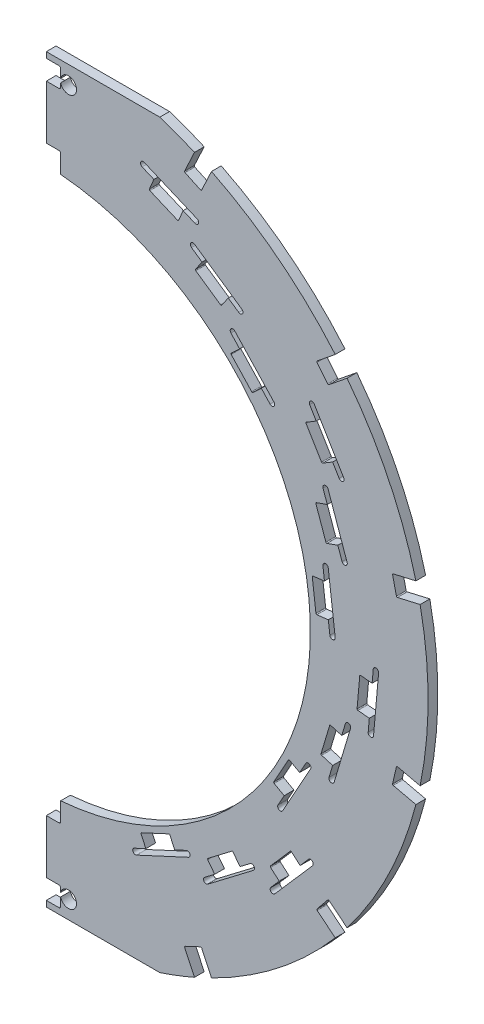
from build123d import *

# Parameters (mm, degrees)
EXTRUDE1_DEPTH                     = 2.715
EXTRUDE3_DEPTH                     = 6.43
CUT_EXTRUDE2_DEPTH                 = 6.43
CIRPATTERN2_COUNT                  = 6
CIRPATTERN2_ANGLE                  = 130
SKETCH9_W                          = 8
SKETCH9_H                          = 11
SKETCH9_H_2                        = 11.120780421
CUT_EXTRUDE3_DEPTH                 = 6.43
FILLET1_R                          = 1
STAVE_MOUNT_HOLE_EXTRUDE4_DEPTH    = 3.715
STAVE_MOUNT_HOLE_CIRPATTERN3_COUNT = 4
STAVE_MOUNT_HOLE_CIRPATTERN3_ANGLE = 108.15757923
CABLE_SLOT_EXTRUDE6_DEPTH          = 6.43
CABLE_SLOT_CIRPATTERN4_COUNT       = 4
CABLE_SLOT_CIRPATTERN4_ANGLE       = 108.15757923
SKETCH15_R                         = 4.5
CUT_EXTRUDE5_DEPTH                 = 8


with BuildPart() as part:
    # Sketch1 → Extrude1 (new body, symmetric)
    with BuildSketch(Plane.XY):
        with BuildLine():
            Line((4.5, 217.548779521), (4.5, 151.827758069))
            ThreePointArc((4.5, 151.827758069), (22.508034536, 150.217530607), (40.197176015, 146.479026351))
            ThreePointArc((40.197176015, 146.479026351), (151.89443084, 0), (40.197176015, -146.479026351))
            ThreePointArc((40.197176015, -146.479026351), (22.508034536, -150.217530607), (4.5, -151.827758069))
            Line((4.5, -151.827758069), (4.5, -217.548779521))
            ThreePointArc((4.5, -217.548779521), (217.59531583, 0), (4.5, 217.548779521))
        make_face()
    extrude(amount=EXTRUDE1_DEPTH, both=True)

    # Sketch3 → Extrude3 (cut, through all)
    with BuildSketch(Plane.XY.offset(2.715)):
        with BuildLine():
            Line((4.5, 217.548779521), (4.5, 206.75))
            Line((4.5, 206.75), (67.839214111, 206.75))
            ThreePointArc((67.839214111, 206.75), (36.570396283, 214.500180855), (4.5, 217.548779521))
        make_face()
        with BuildLine():
            Line((67.839214111, -206.75), (4.5, -206.75))
            Line((4.5, -206.75), (4.5, -217.548779521))
            ThreePointArc((4.5, -217.548779521), (36.570396283, -214.500180855), (67.839214111, -206.75))
        make_face()
    extrude(amount=-EXTRUDE3_DEPTH, mode=Mode.SUBTRACT)

    # Sketch7 → Cut-Extrude2 (cut, through all)
    with BuildSketch(Plane(origin=(0, 0, -2.715), x_dir=(-1, 0, 0), z_dir=(0, 0, -1))):
        with BuildLine():
            Line((-88.244526651, -201.663556413), (-81.693943595, -187.615785714))
            ThreePointArc((-81.693943595, -187.615785714), (-81.677251178, -187.233466511), (-81.935788357, -186.951322689))
            Line((-81.935788357, -186.951322689), (-90.545712334, -182.936449203))
            ThreePointArc((-90.545712334, -182.936449203), (-90.928031537, -182.919756786), (-91.210175358, -183.178293965))
            Line((-91.210175358, -183.178293965), (-97.760758415, -197.226064665))
            Line((-97.760758415, -197.226064665), (-88.244526651, -201.663556413))
        make_face()
    cut_extrude2 = extrude(amount=-CUT_EXTRUDE2_DEPTH, mode=Mode.SUBTRACT)

    # CirPattern2: Cut-Extrude2 ×6 about axis
    cirpattern2_axis = Axis((0, 0, 0), (0, 0, 1))
    for i in range(1, CIRPATTERN2_COUNT):
        add(cut_extrude2.rotate(cirpattern2_axis, i * CIRPATTERN2_ANGLE / (CIRPATTERN2_COUNT - 1)), mode=Mode.SUBTRACT)

    # Sketch9 → Cut-Extrude3 (cut, through all)
    with BuildSketch(Plane.XY.offset(2.715)):
        with Locations((8.5, 198)):
            Rectangle(SKETCH9_W, SKETCH9_H)
        with Locations((8.5, 156.93960979)):
            Rectangle(SKETCH9_W, SKETCH9_H_2)
        with Locations((8.5, -156.93960979)):
            Rectangle(SKETCH9_W, SKETCH9_H_2)
        with Locations((8.5, -198)):
            Rectangle(SKETCH9_W, SKETCH9_H)
    extrude(amount=-CUT_EXTRUDE3_DEPTH, mode=Mode.SUBTRACT)

    # Fillet1
    fillet1_edges = [part.edges().sort_by_distance(p)[0] for p in [
        (12.5, 203.5, 0),
        (12.5, 192.5, 0),
        (12.5, 162.5, 0),
        (12.5, -162.5, 0),
        (12.5, -192.5, 0),
        (12.5, -203.5, 0),
    ]]
    fillet(fillet1_edges, radius=FILLET1_R)

    # Sketch12 → Stave Mount Hole Extrude4 (cut, symmetric)
    with BuildSketch(Plane.XY):
        with BuildLine():
            Line((81.05997002, 168.515925408), (64.717175048, 175.442364068))
            Line((64.717175048, 175.442364068), (62.024643964, 169.089390248))
            ThreePointArc((62.024643964, 169.089390248), (62.021516135, 168.706719598), (62.289893437, 168.433918878))
            Line((62.289893437, 168.433918878), (77.711967566, 161.897702115))
            ThreePointArc((77.711967566, 161.897702115), (78.094638216, 161.894574286), (78.367438936, 162.162951588))
            Line((78.367438936, 162.162951588), (81.05997002, 168.515925408))
        make_face()
        with BuildLine():
            Line((106.331447872, 138.829702645), (91.71020721, 148.893589643))
            Line((91.71020721, 148.893589643), (87.798048321, 143.209839751))
            ThreePointArc((87.798048321, 143.209839751), (87.718223518, 142.835574324), (87.926424481, 142.514484043))
            Line((87.926424481, 142.514484043), (101.723933275, 133.017576594))
            ThreePointArc((101.723933275, 133.017576594), (102.098198702, 132.937751792), (102.419288983, 133.145952754))
            Line((102.419288983, 133.145952754), (106.331447872, 138.829702645))
        make_face()
        with BuildLine():
            Line((124.871960999, 104.378066242), (112.762511581, 117.35588327))
            Line((112.762511581, 117.35588327), (107.717613695, 112.648548004))
            ThreePointArc((107.717613695, 112.648548004), (107.559024207, 112.300272274), (107.693152635, 111.941864442))
            Line((107.693152635, 111.941864442), (119.12037955, 99.695192035))
            ThreePointArc((119.12037955, 99.695192035), (119.46865528, 99.536602548), (119.827063112, 99.670730976))
            Line((119.827063112, 99.670730976), (124.871960999, 104.378066242))
        make_face()
    stave_mount_hole_extrude4 = extrude(amount=STAVE_MOUNT_HOLE_EXTRUDE4_DEPTH, both=True, mode=Mode.SUBTRACT)

    # Stave Mount Hole CirPattern3: Stave Mount Hole Extrude4 ×4 about axis
    stave_mount_hole_cirpattern3_axis = Axis((0, 0, 0), (0, 0, -1))
    for i in range(1, STAVE_MOUNT_HOLE_CIRPATTERN3_COUNT):
        add(stave_mount_hole_extrude4.rotate(stave_mount_hole_cirpattern3_axis, i * STAVE_MOUNT_HOLE_CIRPATTERN3_ANGLE / (STAVE_MOUNT_HOLE_CIRPATTERN3_COUNT - 1)), mode=Mode.SUBTRACT)

    # Sketch14 → Cable Slot Extrude6 (cut, through all)
    with BuildSketch(Plane.XY.offset(2.715)):
        with BuildLine():
            Line((131.560657882, 100.874217072), (109.729537805, 124.270844953))
            ThreePointArc((109.729537805, 124.270844953), (107.609487119, 124.344228131), (107.536103941, 122.224177445))
            Line((107.536103941, 122.224177445), (129.367224018, 98.827549565))
            ThreePointArc((129.367224018, 98.827549565), (131.487274703, 98.754166386), (131.560657882, 100.874217072))
        make_face()
        with BuildLine():
            Line((85.557627874, 152.521452996), (111.917047659, 134.378107423))
            ThreePointArc((111.917047659, 134.378107423), (114.003114786, 134.763235902), (113.617986307, 136.849303028))
            Line((113.617986307, 136.849303028), (87.258566521, 154.992648601))
            ThreePointArc((87.258566521, 154.992648601), (85.172499395, 154.607520122), (85.557627874, 152.521452996))
        make_face()
        with BuildLine():
            Line((57.96192809, 177.762334657), (87.424995082, 165.275233975))
            ThreePointArc((87.424995082, 165.275233975), (89.391409192, 166.070982396), (88.595660771, 168.037396506))
            Line((88.595660771, 168.037396506), (59.132593779, 180.524497188))
            ThreePointArc((59.132593779, 180.524497188), (57.16617967, 179.728748767), (57.96192809, 177.762334657))
        make_face()
    cable_slot_extrude6 = extrude(amount=-CABLE_SLOT_EXTRUDE6_DEPTH, mode=Mode.SUBTRACT)

    # Cable Slot CirPattern4: Cable Slot Extrude6 ×4 about axis
    cable_slot_cirpattern4_axis = Axis((0, 0, 0), (0, 0, -1))
    for i in range(1, CABLE_SLOT_CIRPATTERN4_COUNT):
        add(cable_slot_extrude6.rotate(cable_slot_cirpattern4_axis, i * CABLE_SLOT_CIRPATTERN4_ANGLE / (CABLE_SLOT_CIRPATTERN4_COUNT - 1)), mode=Mode.SUBTRACT)

    # Sketch15 → Cut-Extrude5 (cut)
    with BuildSketch(Plane.XY.offset(2.715)):
        with Locations((16.866246808, 196.75)):
            Circle(SKETCH15_R)
        with Locations((16.866246808, -196.75)):
            Circle(SKETCH15_R)
    extrude(amount=-CUT_EXTRUDE5_DEPTH, mode=Mode.SUBTRACT)


solid = part.part
